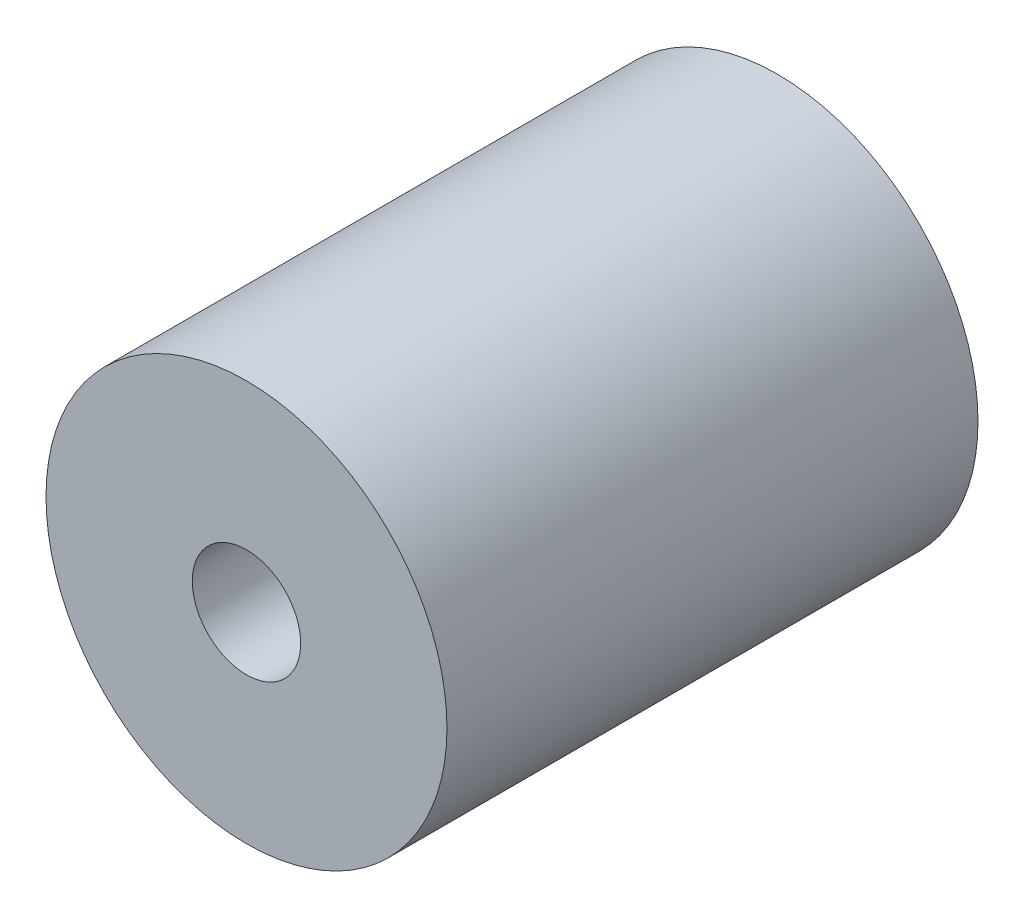
from build123d import *

# Parameters (mm, degrees)
SKETCH1_R               = 9.398
BOSS_EXTRUDE1_DEPTH     = 24.892
SKETCH2_R               = 2.54
CUT_EXTRUDE1_DEPTH      = 1
CUT_EXTRUDE1_DEPTH_BACK = 25.892
SKETCH3_R               = 3.9878
CUT_EXTRUDE2_DEPTH      = 12.446


with BuildPart() as part:
    # Sketch1 → Boss-Extrude1 (new body)
    with BuildSketch(Plane.XY):
        Circle(SKETCH1_R)
    extrude(amount=BOSS_EXTRUDE1_DEPTH)

    # Sketch2 → Cut-Extrude1 (cut, two sides)
    with BuildSketch(Plane(origin=(0, 0, 0), x_dir=(-1, 0, 0), z_dir=(0, 0, -1))) as cut_extrude1_sk:
        Circle(SKETCH2_R)
    extrude(amount=CUT_EXTRUDE1_DEPTH, mode=Mode.SUBTRACT)
    extrude(cut_extrude1_sk.sketch, amount=-CUT_EXTRUDE1_DEPTH_BACK, mode=Mode.SUBTRACT)

    # Sketch3 → Cut-Extrude2 (cut)
    with BuildSketch(Plane(origin=(0, 0, 0), x_dir=(-1, 0, 0), z_dir=(0, 0, -1))):
        Circle(SKETCH3_R)
    extrude(amount=-CUT_EXTRUDE2_DEPTH, mode=Mode.SUBTRACT)


solid = part.part
